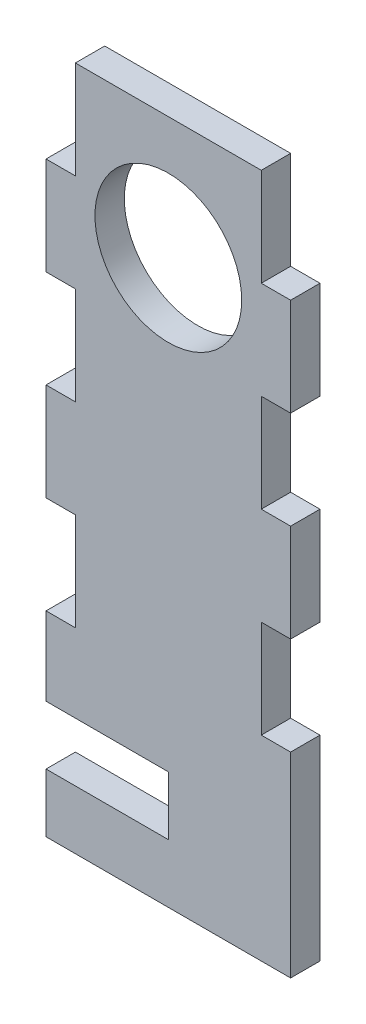
from build123d import *

# Parameters (mm, degrees)
SKETCH1_W           = 25
SKETCH1_H           = 70
BOSS_EXTRUDE1_DEPTH = 3
SKETCH2_R           = 7.5
SKETCH2_W           = 3
SKETCH2_H           = 10
SKETCH2_W_2         = 12.5
SKETCH2_H_2         = 6
CUT_EXTRUDE1_DEPTH  = 3


with BuildPart() as part:
    # Sketch1 → Boss-Extrude1 (new body)
    with BuildSketch(Plane.XY):
        Rectangle(SKETCH1_W, SKETCH1_H)
    extrude(amount=BOSS_EXTRUDE1_DEPTH)

    # Sketch2 → Cut-Extrude1 (cut)
    with BuildSketch(Plane.XY.offset(3)):
        with Locations((0, 22.5)):
            Circle(SKETCH2_R)
        with Locations((-11, -10)):
            Rectangle(SKETCH2_W, SKETCH2_H)
        with Locations((11, 30)):
            Rectangle(SKETCH2_W, SKETCH2_H)
        with Locations((11, 10)):
            Rectangle(SKETCH2_W, SKETCH2_H)
        with Locations((11, -10)):
            Rectangle(SKETCH2_W, SKETCH2_H)
        with Locations((-11, 10)):
            Rectangle(SKETCH2_W, SKETCH2_H)
        with Locations((-11, 30)):
            Rectangle(SKETCH2_W, SKETCH2_H)
        with Locations((-6.25, -26)):
            Rectangle(SKETCH2_W_2, SKETCH2_H_2)
    extrude(amount=-CUT_EXTRUDE1_DEPTH, mode=Mode.SUBTRACT)


solid = part.part
